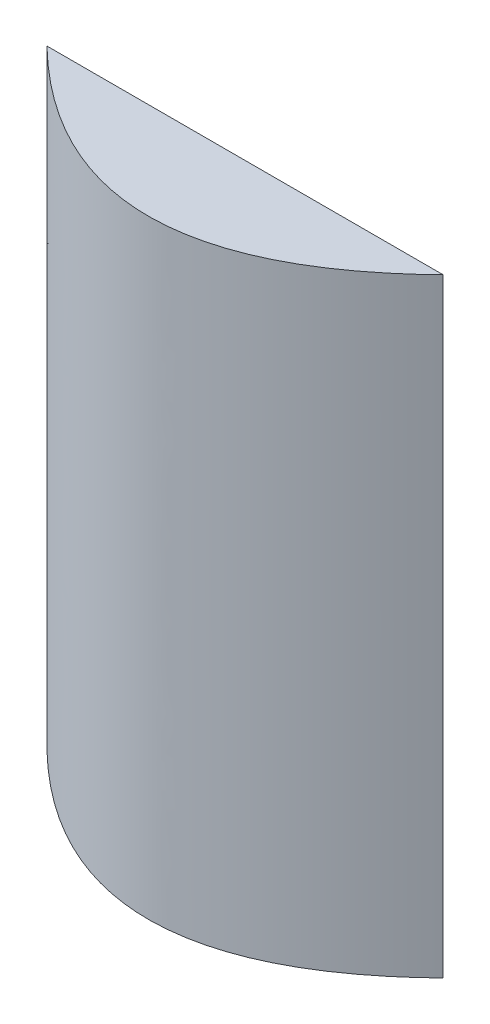
from build123d import *

# Parameters (mm, degrees)
BOSS_EXTRUDE1_DEPTH = 300
SKETCH2_W           = 519.492819312
SKETCH2_H           = 169.467341569
CUT_EXTRUDE1_DEPTH  = 350


with BuildPart() as part:
    # Sketch1 → Boss-Extrude1 (new body)
    with BuildSketch(Plane(origin=(0, 0, 0), x_dir=(1, 0, 0), z_dir=(0, 1, 0))):
        with BuildLine():
            Line((-200, 1e-09), (200, 1e-09))
            add(Edge.make_bspline(
                [(-200, 1e-09), (0, -400.000000001), (200, 1e-09)],
                knots=[0.056028396, 0.056028396, 0.056028396, 0.943971604, 0.943971604, 0.943971604], degree=2))
        make_face()
    extrude(amount=BOSS_EXTRUDE1_DEPTH)

    # Sketch2 → Cut-Extrude1 (cut)
    with BuildSketch(Plane(origin=(0, 300, 0), x_dir=(1, 0, 0), z_dir=(0, 1, 0))):
        with Locations((17.301639584, -67.666329215)):
            Rectangle(SKETCH2_W, SKETCH2_H)
    extrude(amount=-CUT_EXTRUDE1_DEPTH, mode=Mode.SUBTRACT)


solid = part.part
